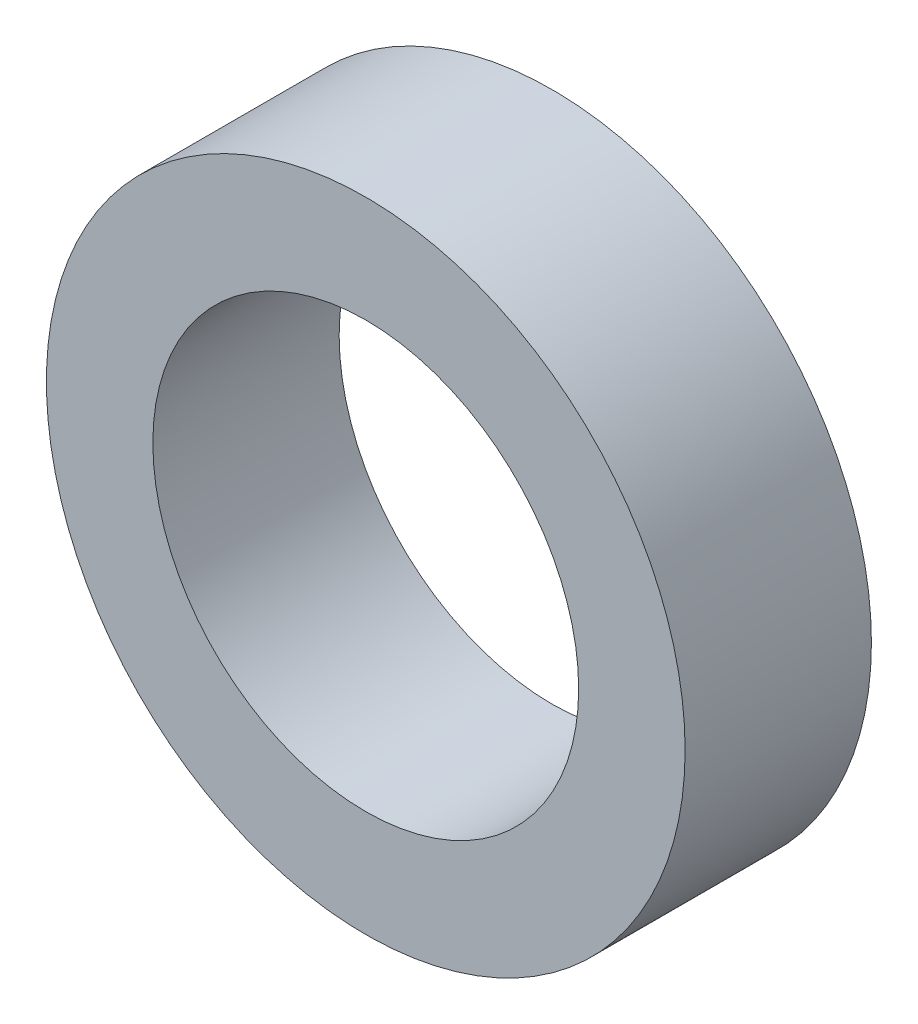
from build123d import *

# Parameters (mm, degrees)
ESQUISSE1_R      = 6
ESQUISSE1_R_2    = 4
EXTRUSION1_DEPTH = 3.5


with BuildPart() as part:
    # Esquisse1 → Extrusion1 (new body)
    with BuildSketch(Plane.XY):
        Circle(ESQUISSE1_R)
        Circle(ESQUISSE1_R_2, mode=Mode.SUBTRACT)
    extrude(amount=EXTRUSION1_DEPTH)


solid = part.part
